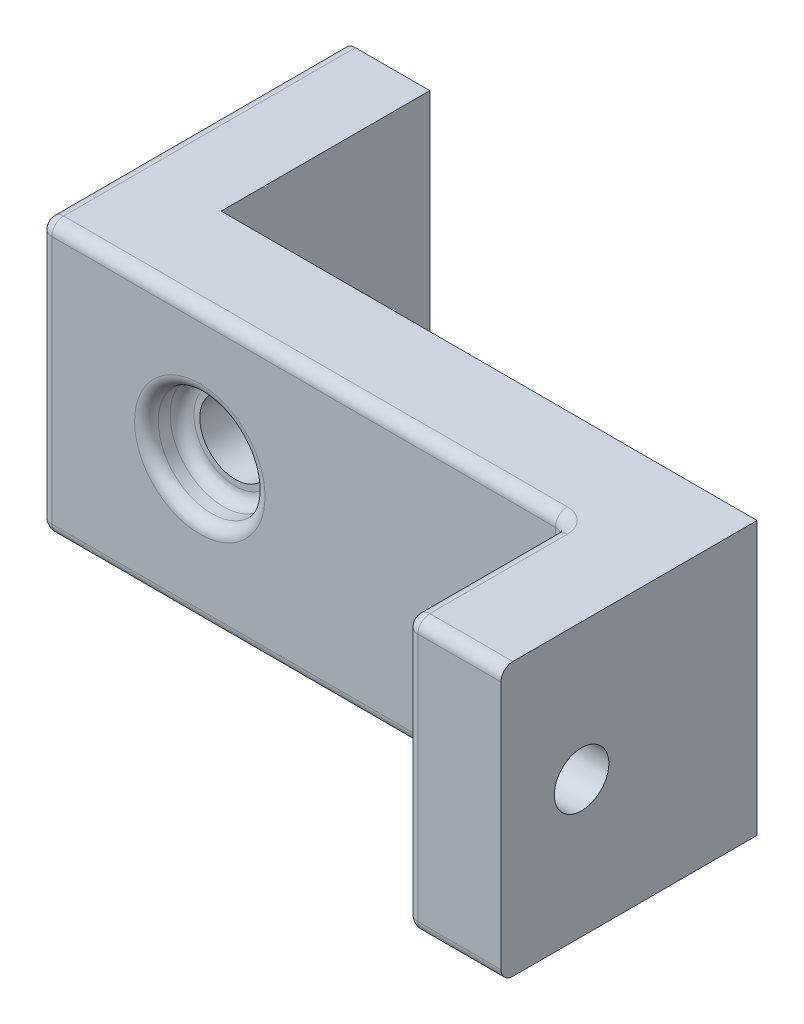
from build123d import *

# Parameters (mm, degrees)
BOSS_EXTRUDE1_DEPTH = 11.5
SKETCH4_R           = 1.5
CUT_EXTRUDE1_DEPTH  = 4.5
SKETCH5_R           = 2.25
CUT_EXTRUDE2_DEPTH  = 1.5
SKETCH6_R           = 2.15
CUT_EXTRUDE3_DEPTH  = 1.75
SKETCH7_R           = 1.15
CUT_EXTRUDE4_DEPTH  = 2.5
FILLET4_R           = 0.5
FILLET5_R           = 0.5
FILLET6_R           = 0.5


with BuildPart() as part:
    # Sketch1 → Boss-Extrude1 (new body)
    with BuildSketch(Plane(origin=(0, 0, 0), x_dir=(1, 0, 0), z_dir=(0, 1, 0))):
        Polygon((0, 0), (0, 12.8), (3.64, 12.8), (3.64, 4), (26.24, 4), (26.24, -6.8), (22.24, -6.8), (22.24, 0), align=None)
    extrude(amount=BOSS_EXTRUDE1_DEPTH)

    # Sketch4 → Cut-Extrude1 (cut)
    with BuildSketch(Plane.XY):
        with Locations((6.74, 6)):
            Circle(SKETCH4_R)
    extrude(amount=-CUT_EXTRUDE1_DEPTH, mode=Mode.SUBTRACT)

    # Sketch5 → Cut-Extrude2 (cut)
    with BuildSketch(Plane.XY):
        with Locations((6.74, 6)):
            Circle(SKETCH5_R)
    extrude(amount=-CUT_EXTRUDE2_DEPTH, mode=Mode.SUBTRACT)

    # Sketch6 → Cut-Extrude3 (cut)
    with BuildSketch(Plane.ZY.offset(-22.24)):
        with Locations((3.4, 5.75)):
            Circle(SKETCH6_R)
    extrude(amount=-CUT_EXTRUDE3_DEPTH, mode=Mode.SUBTRACT)

    # Sketch7 → Cut-Extrude4 (cut)
    with BuildSketch(Plane.ZY.offset(-23.99)):
        with Locations((3.4, 5.75)):
            Circle(SKETCH7_R)
    extrude(amount=-CUT_EXTRUDE4_DEPTH, mode=Mode.SUBTRACT)

    # Fillet4
    fillet4_edges = [part.edges().sort_by_distance(p)[0] for p in [
        (4.49, 6, 0),
        (4.49, 6, -1.5),
    ]]
    fillet(fillet4_edges, radius=FILLET4_R)

    # Fillet5
    fillet5_edges = [part.edges().sort_by_distance(p)[0] for p in [
        (23.99, 5.75, 1.25),
        (22.24, 5.75, 1.25),
    ]]
    fillet(fillet5_edges, radius=FILLET5_R)

    # Fillet6
    fillet6_edges = [part.edges().sort_by_distance(p)[0] for p in [
        (24.24, 11.5, 6.8),
        (22.24, 0, 3.4),
        (11.12, 0, 0),
        (0, 5.75, 0),
        (22.24, 5.75, 6.8),
        (22.24, 5.75, 0),
        (0, 11.5, -6.4),
        (11.12, 11.5, 0),
        (22.24, 11.5, 3.4),
        (0, 0, -6.4),
        (24.24, 0, 6.8),
    ]]
    fillet(fillet6_edges, radius=FILLET6_R)


solid = part.part
